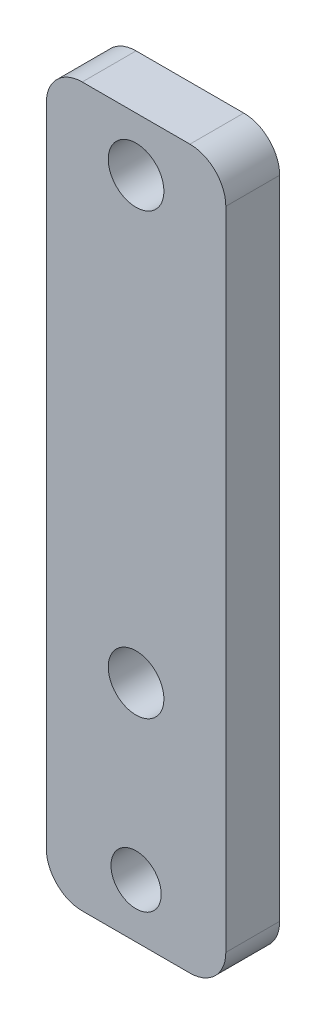
from build123d import *

# Parameters (mm, degrees)
ESQUISSE1_W        = 10
ESQUISSE1_H        = 30
ESQUISSE1_R        = 1.55
BOSS_EXTRU_1_DEPTH = 3
ESQUISSE3_W        = 10
ESQUISSE3_H        = 10
ESQUISSE3_R        = 1.4
BOSS_EXTRU_2_DEPTH = 3
CONG_1_R           = 2


with BuildPart() as part:
    # Esquisse1 → Boss.-Extru.1 (new body)
    with BuildSketch(Plane.XY):
        Rectangle(ESQUISSE1_W, ESQUISSE1_H)
        with Locations((0, 12)):
            Circle(ESQUISSE1_R, mode=Mode.SUBTRACT)
        with Locations((0, -12.5)):
            Circle(ESQUISSE1_R, mode=Mode.SUBTRACT)
    extrude(amount=BOSS_EXTRU_1_DEPTH)

    # Esquisse3 → Boss.-Extru.2 (add)
    with BuildSketch(Plane.XY.offset(3)):
        with Locations((0, -20)):
            Rectangle(ESQUISSE3_W, ESQUISSE3_H)
        with Locations((0, -22)):
            Circle(ESQUISSE3_R, mode=Mode.SUBTRACT)
    extrude(amount=-BOSS_EXTRU_2_DEPTH)

    # Congé1
    cong_1_edges = [part.edges().sort_by_distance(p)[0] for p in [
        (-5, -25, 1.5),
        (5, -25, 1.5),
        (-5, 15, 1.5),
        (5, 15, 1.5),
    ]]
    fillet(cong_1_edges, radius=CONG_1_R)


solid = part.part
